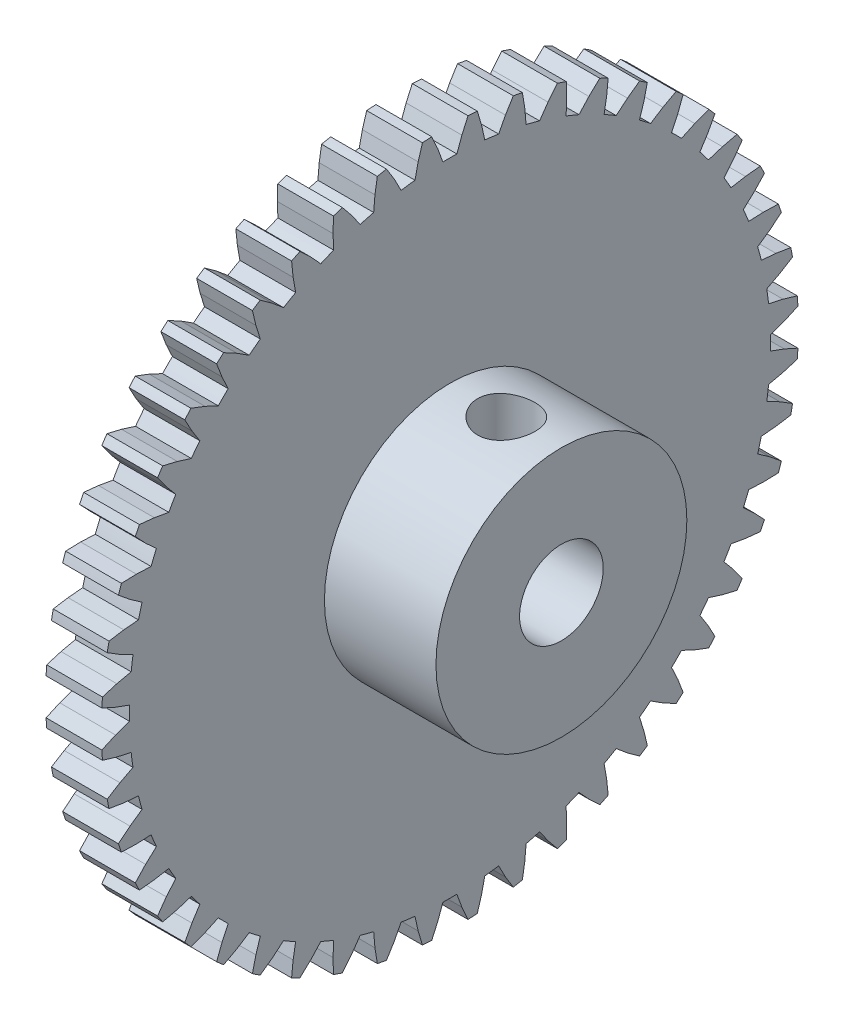
from build123d import *

# Parameters (mm, degrees)
BOSS_EXTRUDE1_DEPTH          = 2
SKETCH2_W                    = 4
SKETCH2_H                    = 4.5
F_3_0_3_DIAMETER_HOLE1_D     = 3
F_3_0_3_DIAMETER_HOLE1_DEPTH = 6
SKETCH5_W                    = 1.025000001
SKETCH5_H                    = 9


with BuildPart() as part:
    # Sketch1 → Boss-Extrude1 (new body)
    with BuildSketch(Plane(origin=(2, 0, 0), x_dir=(0, 0, -1), z_dir=(1, 0, 0))):
        with BuildLine():
            Line((-11.497263311, -0.250871178), (-11.992256243, -0.431033871))
            Line((-11.992256243, -0.431033871), (-12.483028281, -0.651156621))
            ThreePointArc((-12.483028281, -0.651156621), (-12.473236541, -0.817539115), (-12.461227238, -0.983776262))
            Line((-12.461227238, -0.983776262), (-11.945922039, -1.137957227))
            Line((-11.945922039, -1.137957227), (-11.43164789, -1.251969061))
            ThreePointArc((-11.43164789, -1.251969061), (-11.401615906, -1.50105121), (-11.366157371, -1.749418939))
            Line((-11.366157371, -1.749418939), (-11.833399619, -1.99264986))
            Line((-11.833399619, -1.99264986), (-12.291241249, -2.274948035))
            ThreePointArc((-12.291241249, -2.274948035), (-12.259816005, -2.438629025), (-12.226211142, -2.601876461))
            Line((-12.226211142, -2.601876461), (-11.695189796, -2.687477561))
            Line((-11.695189796, -2.687477561), (-11.170433803, -2.733387762))
            ThreePointArc((-11.170433803, -2.733387762), (-11.108147002, -2.976419018), (-11.040573326, -3.21803366))
            Line((-11.040573326, -3.21803366), (-11.472070246, -3.520171058))
            Line((-11.472070246, -3.520171058), (-11.889147672, -3.859814457))
            ThreePointArc((-11.889147672, -3.859814457), (-11.836626619, -4.017993316), (-11.782001183, -4.175457834))
            Line((-11.782001183, -4.175457834), (-11.244349613, -4.191014409))
            Line((-11.244349613, -4.191014409), (-10.718090497, -4.16803744))
            ThreePointArc((-10.718090497, -4.16803744), (-10.624614624, -4.400859471), (-10.52608201, -4.631586932))
            Line((-10.52608201, -4.631586932), (-10.91445057, -4.987461152))
            Line((-10.91445057, -4.987461152), (-11.283627481, -5.378638384))
            ThreePointArc((-11.283627481, -5.378638384), (-11.210909269, -5.528608628), (-11.136197918, -5.677595965))
            Line((-11.136197918, -5.677595965), (-10.601115491, -5.622841839))
            Line((-10.601115491, -5.622841839), (-10.082357691, -5.531370843))
            ThreePointArc((-10.082357691, -5.531370843), (-9.959292144, -5.75), (-9.831486513, -5.965892468))
            Line((-9.831486513, -5.965892468), (-10.17008162, -6.369414404))
            Line((-10.17008162, -6.369414404), (-10.485041297, -6.805432316))
            ThreePointArc((-10.485041297, -6.805432316), (-10.393370154, -6.944627913), (-10.299851218, -7.082588855))
            Line((-10.299851218, -7.082588855), (-9.776493344, -6.958460886))
            Line((-9.776493344, -6.958460886), (-9.274112949, -6.800060956))
            ThreePointArc((-9.274112949, -6.800060956), (-9.123563413, -7.000756433), (-8.968671556, -7.19811993))
            Line((-8.968671556, -7.19811993), (-9.251699753, -7.642385209))
            Line((-9.251699753, -7.642385209), (-9.507053148, -8.115783415))
            ThreePointArc((-9.507053148, -8.115783415), (-9.397997593, -8.241822689), (-9.287271209, -8.366396686))
            Line((-9.287271209, -8.366396686), (-8.784592685, -8.175018738))
            Line((-8.784592685, -8.175018738), (-8.307185564, -7.952400141))
            ThreePointArc((-8.307185564, -7.952400141), (-8.131727984, -8.131727984), (-7.952400141, -8.307185564))
            Line((-7.952400141, -8.307185564), (-8.175018738, -8.784592685))
            Line((-8.175018738, -8.784592685), (-8.366396684, -9.28727121))
            ThreePointArc((-8.366396684, -9.28727121), (-8.241822688, -9.397997595), (-8.115783413, -9.50705315))
            Line((-8.115783413, -9.50705315), (-7.642385209, -9.251699753))
            Line((-7.642385209, -9.251699753), (-7.19811993, -8.968671556))
            ThreePointArc((-7.19811993, -8.968671556), (-7.000756433, -9.123563414), (-6.800060955, -9.27411295))
            Line((-6.800060955, -9.27411295), (-6.958460886, -9.776493344))
            Line((-6.958460886, -9.776493344), (-7.082588854, -10.299851219))
            ThreePointArc((-7.082588854, -10.299851219), (-6.944627914, -10.393370153), (-6.805432319, -10.485041295))
            Line((-6.805432319, -10.485041295), (-6.369414404, -10.17008162))
            Line((-6.369414404, -10.17008162), (-5.965892469, -9.831486513))
            ThreePointArc((-5.965892469, -9.831486513), (-5.749999999, -9.959292144), (-5.531370841, -10.082357691))
            Line((-5.531370841, -10.082357691), (-5.622841839, -10.601115491))
            Line((-5.622841839, -10.601115491), (-5.677595964, -11.136197918))
            ThreePointArc((-5.677595964, -11.136197918), (-5.528608629, -11.210909269), (-5.378638386, -11.28362748))
            Line((-5.378638386, -11.28362748), (-4.987461152, -10.91445057))
            Line((-4.987461152, -10.91445057), (-4.631586933, -10.52608201))
            ThreePointArc((-4.631586933, -10.52608201), (-4.400859471, -10.624614624), (-4.168037438, -10.718090498))
            Line((-4.168037438, -10.718090498), (-4.191014409, -11.244349613))
            Line((-4.191014409, -11.244349613), (-4.175457834, -11.782001183))
            ThreePointArc((-4.175457834, -11.782001183), (-4.017993317, -11.836626618), (-3.859814459, -11.889147671))
            Line((-3.859814459, -11.889147671), (-3.520171058, -11.472070246))
            Line((-3.520171058, -11.472070246), (-3.218033661, -11.040573325))
            ThreePointArc((-3.218033661, -11.040573325), (-2.97641902, -11.108147002), (-2.733387765, -11.170433802))
            Line((-2.733387765, -11.170433802), (-2.687477561, -11.695189796))
            Line((-2.687477561, -11.695189796), (-2.601876462, -12.226211142))
            ThreePointArc((-2.601876462, -12.226211142), (-2.438629026, -12.259816005), (-2.274948036, -12.291241249))
            Line((-2.274948036, -12.291241249), (-1.99264986, -11.833399619))
            Line((-1.99264986, -11.833399619), (-1.749418941, -11.36615737))
            ThreePointArc((-1.749418941, -11.36615737), (-1.501051212, -11.401615906), (-1.251969063, -11.431647889))
            Line((-1.251969063, -11.431647889), (-1.137957227, -11.945922038))
            Line((-1.137957227, -11.945922038), (-0.983776263, -12.461227238))
            ThreePointArc((-0.983776263, -12.461227238), (-0.817539116, -12.473236541), (-0.651156622, -12.483028281))
            Line((-0.651156622, -12.483028281), (-0.431033871, -11.992256243))
            Line((-0.431033871, -11.992256243), (-0.250871178, -11.497263311))
            ThreePointArc((-0.250871178, -11.497263311), (-1e-09, -11.5), (0.250871176, -11.497263311))
            Line((0.250871176, -11.497263311), (0.431033871, -11.992256243))
            Line((0.431033871, -11.992256243), (0.651156621, -12.483028281))
            ThreePointArc((0.651156621, -12.483028281), (0.817539115, -12.473236541), (0.983776263, -12.461227238))
            Line((0.983776263, -12.461227238), (1.137957227, -11.945922038))
            Line((1.137957227, -11.945922038), (1.251969061, -11.431647889))
            ThreePointArc((1.251969061, -11.431647889), (1.50105121, -11.401615906), (1.74941894, -11.36615737))
            Line((1.74941894, -11.36615737), (1.99264986, -11.833399619))
            Line((1.99264986, -11.833399619), (2.274948035, -12.291241249))
            ThreePointArc((2.274948035, -12.291241249), (2.438629025, -12.259816005), (2.601876463, -12.226211141))
            Line((2.601876463, -12.226211141), (2.687477561, -11.695189796))
            Line((2.687477561, -11.695189796), (2.733387762, -11.170433803))
            ThreePointArc((2.733387762, -11.170433803), (2.976419018, -11.108147002), (3.218033661, -11.040573325))
            Line((3.218033661, -11.040573325), (3.520171058, -11.472070246))
            Line((3.520171058, -11.472070246), (3.859814457, -11.889147672))
            ThreePointArc((3.859814457, -11.889147672), (4.017993317, -11.836626619), (4.175457835, -11.782001183))
            Line((4.175457835, -11.782001183), (4.191014409, -11.244349613))
            Line((4.191014409, -11.244349613), (4.16803744, -10.718090497))
            ThreePointArc((4.16803744, -10.718090497), (4.400859472, -10.624614624), (4.631586933, -10.52608201))
            Line((4.631586933, -10.52608201), (4.987461152, -10.91445057))
            Line((4.987461152, -10.91445057), (5.378638384, -11.283627481))
            ThreePointArc((5.378638384, -11.283627481), (5.528608629, -11.210909269), (5.677595966, -11.136197917))
            Line((5.677595966, -11.136197917), (5.622841839, -10.601115491))
            Line((5.622841839, -10.601115491), (5.531370843, -10.08235769))
            ThreePointArc((5.531370843, -10.08235769), (5.75, -9.959292143), (5.965892469, -9.831486512))
            Line((5.965892469, -9.831486512), (6.369414404, -10.17008162))
            Line((6.369414404, -10.17008162), (6.805432316, -10.485041296))
            ThreePointArc((6.805432316, -10.485041296), (6.944627914, -10.393370153), (7.082588856, -10.299851217))
            Line((7.082588856, -10.299851217), (6.958460886, -9.776493344))
            Line((6.958460886, -9.776493344), (6.800060956, -9.274112949))
            ThreePointArc((6.800060956, -9.274112949), (7.000756434, -9.123563413), (7.198119931, -8.968671555))
            Line((7.198119931, -8.968671555), (7.642385209, -9.251699753))
            Line((7.642385209, -9.251699753), (8.115783415, -9.507053148))
            ThreePointArc((8.115783415, -9.507053148), (8.241822687, -9.397997595), (8.366396682, -9.287271212))
            Line((8.366396682, -9.287271212), (8.175018738, -8.784592685))
            Line((8.175018738, -8.784592685), (7.952400141, -8.307185564))
            ThreePointArc((7.952400141, -8.307185564), (8.131727984, -8.131727983), (8.307185565, -7.95240014))
            Line((8.307185565, -7.95240014), (8.784592685, -8.175018738))
            Line((8.784592685, -8.175018738), (9.28727121, -8.366396684))
            ThreePointArc((9.28727121, -8.366396684), (9.397997593, -8.24182269), (9.507053146, -8.115783417))
            Line((9.507053146, -8.115783417), (9.251699753, -7.642385209))
            Line((9.251699753, -7.642385209), (8.968671556, -7.19811993))
            ThreePointArc((8.968671556, -7.19811993), (9.123563414, -7.000756432), (9.27411295, -6.800060954))
            Line((9.27411295, -6.800060954), (9.776493344, -6.958460886))
            Line((9.776493344, -6.958460886), (10.299851219, -7.082588854))
            ThreePointArc((10.299851219, -7.082588854), (10.393370153, -6.944627914), (10.485041295, -6.805432318))
            Line((10.485041295, -6.805432318), (10.17008162, -6.369414404))
            Line((10.17008162, -6.369414404), (9.831486513, -5.965892469))
            ThreePointArc((9.831486513, -5.965892469), (9.959292143, -5.750000001), (10.082357689, -5.531370845))
            Line((10.082357689, -5.531370845), (10.601115491, -5.622841839))
            Line((10.601115491, -5.622841839), (11.136197918, -5.677595964))
            ThreePointArc((11.136197918, -5.677595964), (11.210909269, -5.528608628), (11.283627481, -5.378638385))
            Line((11.283627481, -5.378638385), (10.91445057, -4.987461152))
            Line((10.91445057, -4.987461152), (10.52608201, -4.631586933))
            ThreePointArc((10.52608201, -4.631586933), (10.624614623, -4.400859473), (10.718090496, -4.168037442))
            Line((10.718090496, -4.168037442), (11.244349613, -4.191014409))
            Line((11.244349613, -4.191014409), (11.782001183, -4.175457834))
            ThreePointArc((11.782001183, -4.175457834), (11.836626619, -4.017993317), (11.889147671, -3.859814458))
            Line((11.889147671, -3.859814458), (11.472070246, -3.520171058))
            Line((11.472070246, -3.520171058), (11.040573325, -3.218033661))
            ThreePointArc((11.040573325, -3.218033661), (11.108147002, -2.976419019), (11.170433802, -2.733387763))
            Line((11.170433802, -2.733387763), (11.695189796, -2.687477561))
            Line((11.695189796, -2.687477561), (12.226211141, -2.601876462))
            ThreePointArc((12.226211141, -2.601876462), (12.259816005, -2.438629025), (12.291241249, -2.274948035))
            Line((12.291241249, -2.274948035), (11.833399619, -1.99264986))
            Line((11.833399619, -1.99264986), (11.36615737, -1.749418941))
            ThreePointArc((11.36615737, -1.749418941), (11.401615906, -1.501051211), (11.431647889, -1.251969062))
            Line((11.431647889, -1.251969062), (11.945922038, -1.137957227))
            Line((11.945922038, -1.137957227), (12.461227237, -0.983776263))
            ThreePointArc((12.461227237, -0.983776263), (12.47323654, -0.817539115), (12.483028281, -0.65115662))
            Line((12.483028281, -0.65115662), (11.992256243, -0.431033871))
            Line((11.992256243, -0.431033871), (11.497263311, -0.250871178))
            ThreePointArc((11.497263311, -0.250871178), (11.5, 0), (11.497263311, 0.250871178))
            Line((11.497263311, 0.250871178), (11.992256243, 0.431033871))
            Line((11.992256243, 0.431033871), (12.483028281, 0.651156622))
            ThreePointArc((12.483028281, 0.651156622), (12.47323654, 0.817539116), (12.461227237, 0.983776263))
            Line((12.461227237, 0.983776263), (11.945922038, 1.137957227))
            Line((11.945922038, 1.137957227), (11.431647889, 1.251969063))
            ThreePointArc((11.431647889, 1.251969063), (11.401615905, 1.501051212), (11.36615737, 1.749418941))
            Line((11.36615737, 1.749418941), (11.833399619, 1.99264986))
            Line((11.833399619, 1.99264986), (12.291241249, 2.274948036))
            ThreePointArc((12.291241249, 2.274948036), (12.259816005, 2.438629026), (12.226211141, 2.601876462))
            Line((12.226211141, 2.601876462), (11.695189796, 2.687477561))
            Line((11.695189796, 2.687477561), (11.170433802, 2.733387764))
            ThreePointArc((11.170433802, 2.733387764), (11.108147002, 2.97641902), (11.040573325, 3.218033661))
            Line((11.040573325, 3.218033661), (11.472070246, 3.520171058))
            Line((11.472070246, 3.520171058), (11.889147671, 3.859814459))
            ThreePointArc((11.889147671, 3.859814459), (11.836626618, 4.017993317), (11.782001183, 4.175457834))
            Line((11.782001183, 4.175457834), (11.244349613, 4.191014409))
            Line((11.244349613, 4.191014409), (10.718090498, 4.168037438))
            ThreePointArc((10.718090498, 4.168037438), (10.624614624, 4.400859471), (10.52608201, 4.631586933))
            Line((10.52608201, 4.631586933), (10.91445057, 4.987461152))
            Line((10.91445057, 4.987461152), (11.28362748, 5.378638386))
            ThreePointArc((11.28362748, 5.378638386), (11.210909269, 5.528608629), (11.136197918, 5.677595964))
            Line((11.136197918, 5.677595964), (10.601115491, 5.622841839))
            Line((10.601115491, 5.622841839), (10.082357691, 5.531370841))
            ThreePointArc((10.082357691, 5.531370841), (9.959292144, 5.749999999), (9.831486513, 5.965892469))
            Line((9.831486513, 5.965892469), (10.17008162, 6.369414404))
            Line((10.17008162, 6.369414404), (10.485041295, 6.805432319))
            ThreePointArc((10.485041295, 6.805432319), (10.393370153, 6.944627914), (10.299851219, 7.082588854))
            Line((10.299851219, 7.082588854), (9.776493344, 6.958460886))
            Line((9.776493344, 6.958460886), (9.27411295, 6.800060955))
            ThreePointArc((9.27411295, 6.800060955), (9.123563414, 7.000756433), (8.968671556, 7.19811993))
            Line((8.968671556, 7.19811993), (9.251699753, 7.642385209))
            Line((9.251699753, 7.642385209), (9.50705315, 8.115783413))
            ThreePointArc((9.50705315, 8.115783413), (9.397997595, 8.241822688), (9.28727121, 8.366396684))
            Line((9.28727121, 8.366396684), (8.784592685, 8.175018738))
            Line((8.784592685, 8.175018738), (8.307185564, 7.952400141))
            ThreePointArc((8.307185564, 7.952400141), (8.131727984, 8.131727983), (7.952400141, 8.307185564))
            Line((7.952400141, 8.307185564), (8.175018738, 8.784592685))
            Line((8.175018738, 8.784592685), (8.366396686, 9.287271208))
            ThreePointArc((8.366396686, 9.287271208), (8.241822689, 9.397997593), (8.115783415, 9.507053148))
            Line((8.115783415, 9.507053148), (7.642385209, 9.251699753))
            Line((7.642385209, 9.251699753), (7.19811993, 8.968671555))
            ThreePointArc((7.19811993, 8.968671555), (7.000756433, 9.123563413), (6.800060956, 9.274112949))
            Line((6.800060956, 9.274112949), (6.958460886, 9.776493344))
            Line((6.958460886, 9.776493344), (7.082588855, 10.299851218))
            ThreePointArc((7.082588855, 10.299851218), (6.944627913, 10.393370153), (6.805432316, 10.485041296))
            Line((6.805432316, 10.485041296), (6.369414404, 10.17008162))
            Line((6.369414404, 10.17008162), (5.965892468, 9.831486513))
            ThreePointArc((5.965892468, 9.831486513), (5.75, 9.959292143), (5.531370843, 10.08235769))
            Line((5.531370843, 10.08235769), (5.622841839, 10.601115491))
            Line((5.622841839, 10.601115491), (5.677595965, 11.136197918))
            ThreePointArc((5.677595965, 11.136197918), (5.528608628, 11.210909269), (5.378638384, 11.283627481))
            Line((5.378638384, 11.283627481), (4.987461152, 10.91445057))
            Line((4.987461152, 10.91445057), (4.631586932, 10.52608201))
            ThreePointArc((4.631586932, 10.52608201), (4.400859471, 10.624614624), (4.16803744, 10.718090497))
            Line((4.16803744, 10.718090497), (4.191014409, 11.244349613))
            Line((4.191014409, 11.244349613), (4.175457834, 11.782001183))
            ThreePointArc((4.175457834, 11.782001183), (4.017993316, 11.836626619), (3.859814457, 11.889147672))
            Line((3.859814457, 11.889147672), (3.520171058, 11.472070246))
            Line((3.520171058, 11.472070246), (3.21803366, 11.040573326))
            ThreePointArc((3.21803366, 11.040573326), (2.976419018, 11.108147002), (2.733387762, 11.170433803))
            Line((2.733387762, 11.170433803), (2.687477561, 11.695189796))
            Line((2.687477561, 11.695189796), (2.601876461, 12.226211142))
            ThreePointArc((2.601876461, 12.226211142), (2.438629025, 12.259816005), (2.274948035, 12.291241249))
            Line((2.274948035, 12.291241249), (1.99264986, 11.833399619))
            Line((1.99264986, 11.833399619), (1.749418939, 11.366157371))
            ThreePointArc((1.749418939, 11.366157371), (1.50105121, 11.401615906), (1.251969061, 11.431647889))
            Line((1.251969061, 11.431647889), (1.137957227, 11.945922038))
            Line((1.137957227, 11.945922038), (0.983776262, 12.461227238))
            ThreePointArc((0.983776262, 12.461227238), (0.817539115, 12.473236541), (0.651156621, 12.483028281))
            Line((0.651156621, 12.483028281), (0.431033871, 11.992256243))
            Line((0.431033871, 11.992256243), (0.250871175, 11.497263311))
            ThreePointArc((0.250871175, 11.497263311), (-1e-09, 11.5), (-0.250871178, 11.497263311))
            Line((-0.250871178, 11.497263311), (-0.431033871, 11.992256243))
            Line((-0.431033871, 11.992256243), (-0.651156623, 12.483028281))
            ThreePointArc((-0.651156623, 12.483028281), (-0.817539116, 12.473236541), (-0.983776263, 12.461227238))
            Line((-0.983776263, 12.461227238), (-1.137957227, 11.945922038))
            Line((-1.137957227, 11.945922038), (-1.251969058, 11.43164789))
            ThreePointArc((-1.251969058, 11.43164789), (-1.501051209, 11.401615906), (-1.749418941, 11.36615737))
            Line((-1.749418941, 11.36615737), (-1.99264986, 11.833399619))
            Line((-1.99264986, 11.833399619), (-2.274948037, 12.291241249))
            ThreePointArc((-2.274948037, 12.291241249), (-2.438629026, 12.259816005), (-2.601876462, 12.226211142))
            Line((-2.601876462, 12.226211142), (-2.687477561, 11.695189796))
            Line((-2.687477561, 11.695189796), (-2.73338776, 11.170433803))
            ThreePointArc((-2.73338776, 11.170433803), (-2.976419018, 11.108147002), (-3.218033661, 11.040573325))
            Line((-3.218033661, 11.040573325), (-3.520171058, 11.472070246))
            Line((-3.520171058, 11.472070246), (-3.85981446, 11.889147671))
            ThreePointArc((-3.85981446, 11.889147671), (-4.017993318, 11.836626618), (-4.175457834, 11.782001183))
            Line((-4.175457834, 11.782001183), (-4.191014409, 11.244349613))
            Line((-4.191014409, 11.244349613), (-4.168037439, 10.718090497))
            ThreePointArc((-4.168037439, 10.718090497), (-4.400859471, 10.624614624), (-4.631586933, 10.52608201))
            Line((-4.631586933, 10.52608201), (-4.987461152, 10.91445057))
            Line((-4.987461152, 10.91445057), (-5.378638382, 11.283627482))
            ThreePointArc((-5.378638382, 11.283627482), (-5.528608627, 11.21090927), (-5.677595964, 11.136197918))
            Line((-5.677595964, 11.136197918), (-5.622841839, 10.601115491))
            Line((-5.622841839, 10.601115491), (-5.531370842, 10.082357691))
            ThreePointArc((-5.531370842, 10.082357691), (-5.75, 9.959292144), (-5.965892469, 9.831486513))
            Line((-5.965892469, 9.831486513), (-6.369414404, 10.17008162))
            Line((-6.369414404, 10.17008162), (-6.805432315, 10.485041298))
            ThreePointArc((-6.805432315, 10.485041298), (-6.944627912, 10.393370154), (-7.082588854, 10.299851219))
            Line((-7.082588854, 10.299851219), (-6.958460886, 9.776493344))
            Line((-6.958460886, 9.776493344), (-6.800060956, 9.274112949))
            ThreePointArc((-6.800060956, 9.274112949), (-7.000756433, 9.123563414), (-7.19811993, 8.968671556))
            Line((-7.19811993, 8.968671556), (-7.642385209, 9.251699753))
            Line((-7.642385209, 9.251699753), (-8.115783414, 9.507053149))
            ThreePointArc((-8.115783414, 9.507053149), (-8.241822688, 9.397997594), (-8.366396684, 9.28727121))
            Line((-8.366396684, 9.28727121), (-8.175018738, 8.784592685))
            Line((-8.175018738, 8.784592685), (-7.952400142, 8.307185564))
            ThreePointArc((-7.952400142, 8.307185564), (-8.131727984, 8.131727983), (-8.307185564, 7.952400141))
            Line((-8.307185564, 7.952400141), (-8.784592685, 8.175018738))
            Line((-8.784592685, 8.175018738), (-9.287271209, 8.366396685))
            ThreePointArc((-9.287271209, 8.366396685), (-9.397997594, 8.241822689), (-9.507053148, 8.115783415))
            Line((-9.507053148, 8.115783415), (-9.251699753, 7.642385209))
            Line((-9.251699753, 7.642385209), (-8.968671556, 7.198119929))
            ThreePointArc((-8.968671556, 7.198119929), (-9.123563414, 7.000756433), (-9.274112949, 6.800060956))
            Line((-9.274112949, 6.800060956), (-9.776493344, 6.958460886))
            Line((-9.776493344, 6.958460886), (-10.299851219, 7.082588854))
            ThreePointArc((-10.299851219, 7.082588854), (-10.393370154, 6.944627913), (-10.485041297, 6.805432316))
            Line((-10.485041297, 6.805432316), (-10.17008162, 6.369414404))
            Line((-10.17008162, 6.369414404), (-9.831486514, 5.965892468))
            ThreePointArc((-9.831486514, 5.965892468), (-9.959292144, 5.749999999), (-10.082357691, 5.531370843))
            Line((-10.082357691, 5.531370843), (-10.601115491, 5.622841839))
            Line((-10.601115491, 5.622841839), (-11.136197918, 5.677595964))
            ThreePointArc((-11.136197918, 5.677595964), (-11.210909269, 5.528608628), (-11.283627481, 5.378638384))
            Line((-11.283627481, 5.378638384), (-10.91445057, 4.987461152))
            Line((-10.91445057, 4.987461152), (-10.526082011, 4.631586931))
            ThreePointArc((-10.526082011, 4.631586931), (-10.624614624, 4.400859471), (-10.718090497, 4.16803744))
            Line((-10.718090497, 4.16803744), (-11.244349613, 4.191014409))
            Line((-11.244349613, 4.191014409), (-11.782001184, 4.175457833))
            ThreePointArc((-11.782001184, 4.175457833), (-11.836626619, 4.017993316), (-11.889147672, 3.859814457))
            Line((-11.889147672, 3.859814457), (-11.472070246, 3.520171058))
            Line((-11.472070246, 3.520171058), (-11.040573326, 3.218033659))
            ThreePointArc((-11.040573326, 3.218033659), (-11.108147003, 2.976419018), (-11.170433803, 2.733387762))
            Line((-11.170433803, 2.733387762), (-11.695189796, 2.687477561))
            Line((-11.695189796, 2.687477561), (-12.226211142, 2.60187646))
            ThreePointArc((-12.226211142, 2.60187646), (-12.259816005, 2.438629024), (-12.291241249, 2.274948035))
            Line((-12.291241249, 2.274948035), (-11.833399619, 1.99264986))
            Line((-11.833399619, 1.99264986), (-11.36615737, 1.749418944))
            ThreePointArc((-11.36615737, 1.749418944), (-11.401615906, 1.501051212), (-11.43164789, 1.251969061))
            Line((-11.43164789, 1.251969061), (-11.945922038, 1.137957227))
            Line((-11.945922038, 1.137957227), (-12.461227238, 0.983776261))
            ThreePointArc((-12.461227238, 0.983776261), (-12.473236541, 0.817539114), (-12.483028281, 0.651156621))
            Line((-12.483028281, 0.651156621), (-11.992256243, 0.431033871))
            Line((-11.992256243, 0.431033871), (-11.497263311, 0.25087118))
            ThreePointArc((-11.497263311, 0.25087118), (-11.5, 1e-09), (-11.497263311, -0.250871178))
        make_face()
    extrude(amount=-BOSS_EXTRUDE1_DEPTH)

    # Sketch2 → Revolve1 (revolve)
    with BuildSketch(Plane.XY):
        with Locations((4, 2.25)):
            Rectangle(SKETCH2_W, SKETCH2_H)
    revolve(axis=Axis((2, 0, 0), (1, 0, 0)))

    # Ø3.0 (3) Diameter Hole1
    with Locations(Plane(origin=(6, 0, 0), x_dir=(0, 0, -1), z_dir=(1, 0, 0))):
        with Locations((0, 0)):
            Hole(F_3_0_3_DIAMETER_HOLE1_D / 2, depth=F_3_0_3_DIAMETER_HOLE1_DEPTH)

    # Sketch5 → Ø2.05 (2.05) Diameter Hole1 (revolve, cut)
    with BuildSketch(Plane(origin=(4, 1.095142532, -0.006150956), x_dir=(0, -0.005616492, -0.999984227), z_dir=(1, 0, 0))):
        with Locations((0.5125, 4.5)):
            Rectangle(SKETCH5_W, SKETCH5_H)
    revolve(axis=Axis((4, -5.254757312, 0.029513766), (0, 0.999984227, -0.005616492)), mode=Mode.SUBTRACT)


solid = part.part
